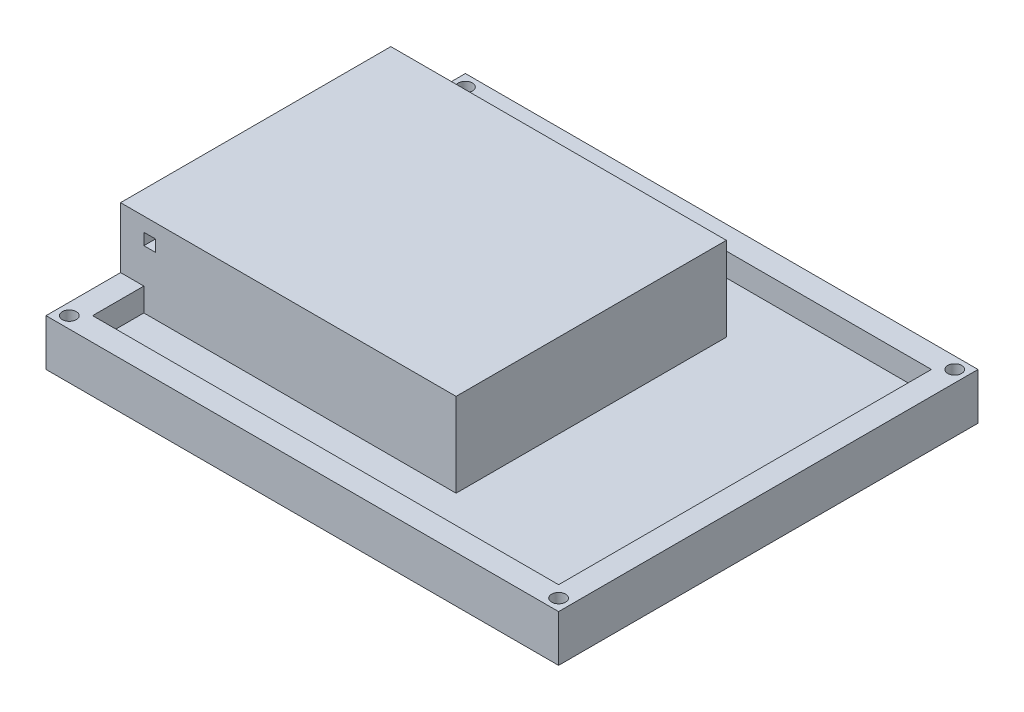
from build123d import *

# Parameters (mm, degrees)
SKETCH1_W            = 110
SKETCH1_H            = 90
BOSS_EXTRUDE2_DEPTH  = 5
SKETCH2_W            = 110
SKETCH2_H            = 5
BOSS_EXTRUDE4_DEPTH  = 25
SKETCH3_W            = 110
SKETCH3_H            = 5
BOSS_EXTRUDE5_DEPTH  = 25
SKETCH5_W            = 5
SKETCH5_H            = 80
BOSS_EXTRUDE6_DEPTH  = 25
SKETCH8_W            = 72
SKETCH8_H            = 58
BOSS_EXTRUDE7_DEPTH  = 25
SKETCH10_W           = 52
SKETCH10_H           = 20.115523146
CUT_EXTRUDE1_DEPTH   = 70
SKETCH11_W           = 90
SKETCH11_H           = 7
CUT_EXTRUDE2_DEPTH   = 110
SKETCH12_R           = 1.5
CUT_EXTRUDE3_DEPTH   = 23
SKETCH13_R           = 1.5
CUT_EXTRUDE4_DEPTH   = 23
SKETCH14_R           = 1.5
CUT_EXTRUDE5_DEPTH   = 23
SKETCH15_R           = 1.5
CUT_EXTRUDE6_DEPTH   = 23
SKETCH18_W           = 5
SKETCH18_H           = 13
CUT_EXTRUDE7_DEPTH   = 110
SKETCH19_W           = 5
SKETCH19_H           = 13
CUT_EXTRUDE13_DEPTH  = 85
SKETCH26_W           = 5
SKETCH26_H           = 13
CUT_EXTRUDE17_DEPTH  = 105
SKETCH29_W           = 5
SKETCH29_H           = 11
BOSS_EXTRUDE14_DEPTH = 5
SKETCH30_W           = 5
SKETCH30_H           = 11
BOSS_EXTRUDE15_DEPTH = 5
SKETCH34_W           = 2.5
SKETCH34_H           = 2.5
CUT_EXTRUDE18_DEPTH  = 3
SKETCH37_W           = 72
SKETCH37_H           = 13
CUT_EXTRUDE20_DEPTH  = 58
SKETCH39_W           = 72
SKETCH39_H           = 3
BOSS_EXTRUDE17_DEPTH = 13
SKETCH41_W           = 2
SKETCH41_H           = 55
BOSS_EXTRUDE18_DEPTH = 13
SKETCH43_W           = 70
SKETCH43_H           = 3
BOSS_EXTRUDE19_DEPTH = 13
SKETCH44_W           = 70
SKETCH44_H           = 52
BOSS_EXTRUDE22_DEPTH = 3
SKETCH55_W           = 2.5
SKETCH55_H           = 2.5
CUT_EXTRUDE25_DEPTH  = 3


with BuildPart() as part:
    # Sketch1 → Boss-Extrude2 (new body)
    with BuildSketch(Plane(origin=(0, 0, 0), x_dir=(1, 0, 0), z_dir=(0, 1, 0))):
        Rectangle(SKETCH1_W, SKETCH1_H)
    extrude(amount=BOSS_EXTRUDE2_DEPTH)

    # Sketch2 → Boss-Extrude4 (add)
    with BuildSketch(Plane(origin=(0, 5, 0), x_dir=(1, 0, 0), z_dir=(0, 1, 0))):
        with Locations((0, 42.5)):
            Rectangle(SKETCH2_W, SKETCH2_H)
    extrude(amount=BOSS_EXTRUDE4_DEPTH)

    # Sketch3 → Boss-Extrude5 (add)
    with BuildSketch(Plane(origin=(0, 5, 0), x_dir=(1, 0, 0), z_dir=(0, 1, 0))):
        with Locations((0, -42.5)):
            Rectangle(SKETCH3_W, SKETCH3_H)
    extrude(amount=BOSS_EXTRUDE5_DEPTH)

    # Sketch5 → Boss-Extrude6 (add)
    with BuildSketch(Plane(origin=(0, 5, 0), x_dir=(1, 0, 0), z_dir=(0, 1, 0))):
        with Locations((52.5, 0)):
            Rectangle(SKETCH5_W, SKETCH5_H)
    extrude(amount=BOSS_EXTRUDE6_DEPTH)

    # Sketch8 → Boss-Extrude7 (add)
    with BuildSketch(Plane(origin=(0, 5, 0), x_dir=(1, 0, 0), z_dir=(0, 1, 0))):
        with Locations((-19, 0)):
            Rectangle(SKETCH8_W, SKETCH8_H)
    extrude(amount=BOSS_EXTRUDE7_DEPTH)

    # Sketch10 → Cut-Extrude1 (cut)
    with BuildSketch(Plane.ZY.offset(55)):
        with Locations((0, 10.057761573)):
            Rectangle(SKETCH10_W, SKETCH10_H)
    extrude(amount=-CUT_EXTRUDE1_DEPTH, mode=Mode.SUBTRACT)

    # Sketch11 → Cut-Extrude2 (cut)
    with BuildSketch(Plane.ZY.offset(55)):
        with Locations((0, 26.5)):
            Rectangle(SKETCH11_W, SKETCH11_H)
    extrude(amount=-CUT_EXTRUDE2_DEPTH, mode=Mode.SUBTRACT)

    # Sketch12 → Cut-Extrude3 (cut)
    with BuildSketch(Plane(origin=(0, 23, 0), x_dir=(1, 0, 0), z_dir=(0, 1, 0))):
        with Locations((52.5, -42.5)):
            Circle(SKETCH12_R)
    extrude(amount=-CUT_EXTRUDE3_DEPTH, mode=Mode.SUBTRACT)

    # Sketch13 → Cut-Extrude4 (cut)
    with BuildSketch(Plane(origin=(0, 23, 0), x_dir=(1, 0, 0), z_dir=(0, 1, 0))):
        with Locations((-52.5, -42.5)):
            Circle(SKETCH13_R)
    extrude(amount=-CUT_EXTRUDE4_DEPTH, mode=Mode.SUBTRACT)

    # Sketch14 → Cut-Extrude5 (cut)
    with BuildSketch(Plane(origin=(0, 23, 0), x_dir=(1, 0, 0), z_dir=(0, 1, 0))):
        with Locations((52.5, 42.5)):
            Circle(SKETCH14_R)
    extrude(amount=-CUT_EXTRUDE5_DEPTH, mode=Mode.SUBTRACT)

    # Sketch15 → Cut-Extrude6 (cut)
    with BuildSketch(Plane(origin=(0, 23, 0), x_dir=(1, 0, 0), z_dir=(0, 1, 0))):
        with Locations((-52.5, 42.5)):
            Circle(SKETCH15_R)
    extrude(amount=-CUT_EXTRUDE6_DEPTH, mode=Mode.SUBTRACT)

    # Sketch18 → Cut-Extrude7 (cut)
    with BuildSketch(Plane.ZY.offset(55)):
        with Locations((-42.5, 16.5)):
            Rectangle(SKETCH18_W, SKETCH18_H)
    extrude(amount=-CUT_EXTRUDE7_DEPTH, mode=Mode.SUBTRACT)

    # Sketch19 → Cut-Extrude13 (cut)
    with BuildSketch(Plane(origin=(0, 0, -40), x_dir=(-1, 0, 0), z_dir=(0, 0, -1))):
        with Locations((-52.5, 16.5)):
            Rectangle(SKETCH19_W, SKETCH19_H)
    extrude(amount=-CUT_EXTRUDE13_DEPTH, mode=Mode.SUBTRACT)

    # Sketch26 → Cut-Extrude17 (cut)
    with BuildSketch(Plane(origin=(50, 0, 0), x_dir=(0, 0, -1), z_dir=(1, 0, 0))):
        with Locations((-42.5, 16.5)):
            Rectangle(SKETCH26_W, SKETCH26_H)
    extrude(amount=-CUT_EXTRUDE17_DEPTH, mode=Mode.SUBTRACT)

    # Sketch29 → Boss-Extrude14 (add)
    with BuildSketch(Plane(origin=(0, 5, 0), x_dir=(1, 0, 0), z_dir=(0, 1, 0))):
        with Locations((-52.5, 34.5)):
            Rectangle(SKETCH29_W, SKETCH29_H)
    extrude(amount=BOSS_EXTRUDE14_DEPTH)

    # Sketch30 → Boss-Extrude15 (add)
    with BuildSketch(Plane(origin=(0, 5, 0), x_dir=(1, 0, 0), z_dir=(0, 1, 0))):
        with Locations((-52.5, -34.5)):
            Rectangle(SKETCH30_W, SKETCH30_H)
    extrude(amount=BOSS_EXTRUDE15_DEPTH)

    # Sketch34 → Cut-Extrude18 (cut)
    with BuildSketch(Plane.XY.offset(29)):
        with Locations((-48.75, 18.75)):
            Rectangle(SKETCH34_W, SKETCH34_H)
    extrude(amount=-CUT_EXTRUDE18_DEPTH, mode=Mode.SUBTRACT)

    # Sketch37 → Cut-Extrude20 (cut)
    with BuildSketch(Plane.XY.offset(29)):
        with Locations((-19, 16.5)):
            Rectangle(SKETCH37_W, SKETCH37_H)
    extrude(amount=-CUT_EXTRUDE20_DEPTH, mode=Mode.SUBTRACT)

    # Sketch39 → Boss-Extrude17 (add)
    with BuildSketch(Plane(origin=(0, 10, 0), x_dir=(1, 0, 0), z_dir=(0, 1, 0))):
        with Locations((-19, 27.5)):
            Rectangle(SKETCH39_W, SKETCH39_H)
    extrude(amount=BOSS_EXTRUDE17_DEPTH)

    # Sketch41 → Boss-Extrude18 (add)
    with BuildSketch(Plane(origin=(0, 10, 0), x_dir=(1, 0, 0), z_dir=(0, 1, 0))):
        with Locations((16, -1.5)):
            Rectangle(SKETCH41_W, SKETCH41_H)
    extrude(amount=BOSS_EXTRUDE18_DEPTH)

    # Sketch43 → Boss-Extrude19 (add)
    with BuildSketch(Plane(origin=(0, 10, 0), x_dir=(1, 0, 0), z_dir=(0, 1, 0))):
        with Locations((-20, -27.5)):
            Rectangle(SKETCH43_W, SKETCH43_H)
    extrude(amount=BOSS_EXTRUDE19_DEPTH)

    # Sketch44 → Boss-Extrude22 (add)
    with BuildSketch(Plane(origin=(0, 23, 0), x_dir=(1, 0, 0), z_dir=(0, 1, 0))):
        with Locations((-20, 0)):
            Rectangle(SKETCH44_W, SKETCH44_H)
    extrude(amount=-BOSS_EXTRUDE22_DEPTH)

    # Sketch55 → Cut-Extrude25 (cut)
    with BuildSketch(Plane.XY.offset(29)):
        with Locations((-48.75, 18.75)):
            Rectangle(SKETCH55_W, SKETCH55_H)
    extrude(amount=-CUT_EXTRUDE25_DEPTH, mode=Mode.SUBTRACT)


solid = part.part
